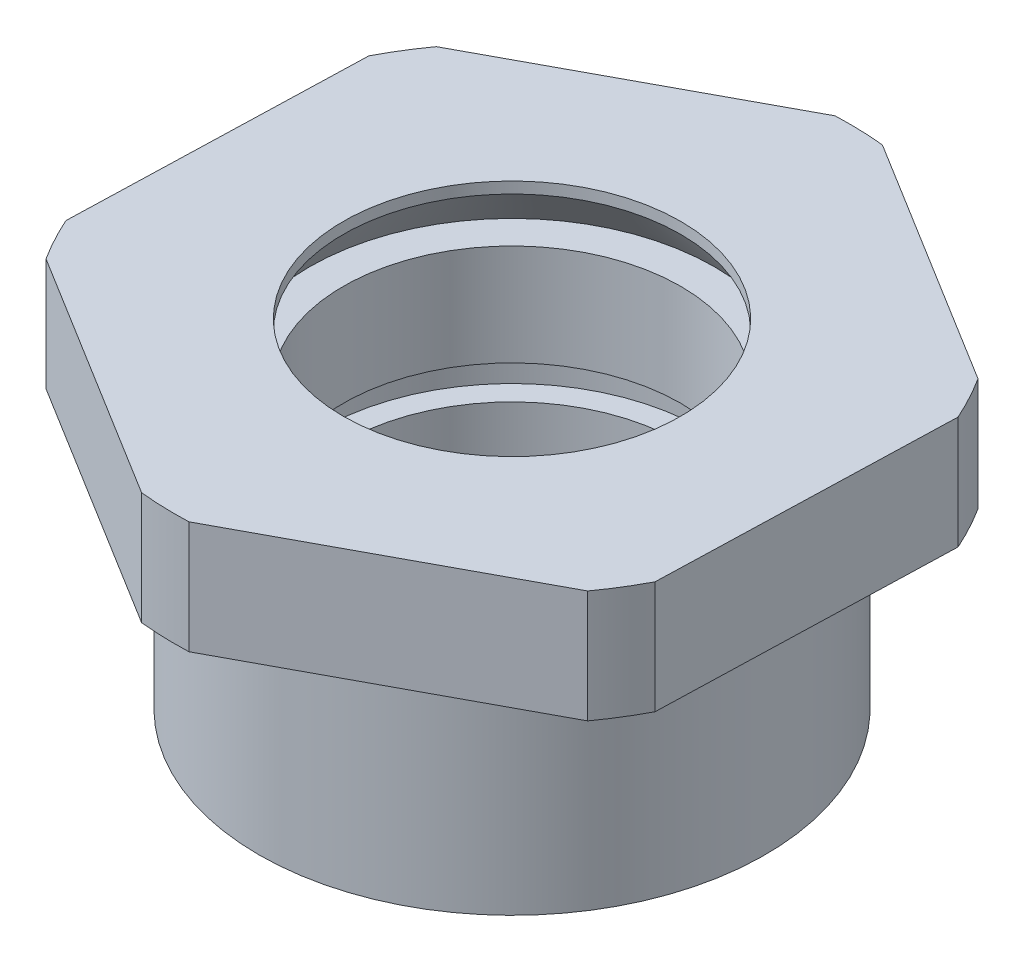
from build123d import *

# Parameters (mm, degrees)
SKETCH3_OUTSIDE_W  = 80
SKETCH3_OUTSIDE_H  = 80
CUT_EXTRUDE1_DEPTH = 31


with BuildPart() as part:
    # Sketch2 → Revolve1 (revolve)
    with BuildSketch(Plane.XY):
        Polygon((22.5, 0), (22.5, 17), (21, 17), (21, 20), (30, 20), (30, 30), (15, 30), (15, 29), (18, 25), (15, 25), (15, 16), (17, 16), (17, 13), (15, 13), (15, 8), (17, 8), (17, 5), (15, 5), (15, 0), align=None)
    revolve(axis=Axis((0, 16.306451613, 0), (0, -1, 0)))

    # Sketch3 outside → Cut-Extrude1 (cut, through all)
    with BuildSketch(Plane(origin=(0, 30, 0), x_dir=(1, 0, 0), z_dir=(0, 1, 0))):
        Rectangle(SKETCH3_OUTSIDE_W, SKETCH3_OUTSIDE_H)
        Polygon((0.936055849, 31.162859295), (-26.51979988, 16.392077792), (-27.455855728, -14.770781503), (-0.936055849, -31.162859295), (26.51979988, -16.392077792), (27.455855728, 14.770781503), align=None, mode=Mode.SUBTRACT)
    extrude(amount=-CUT_EXTRUDE1_DEPTH, mode=Mode.SUBTRACT)


solid = part.part
